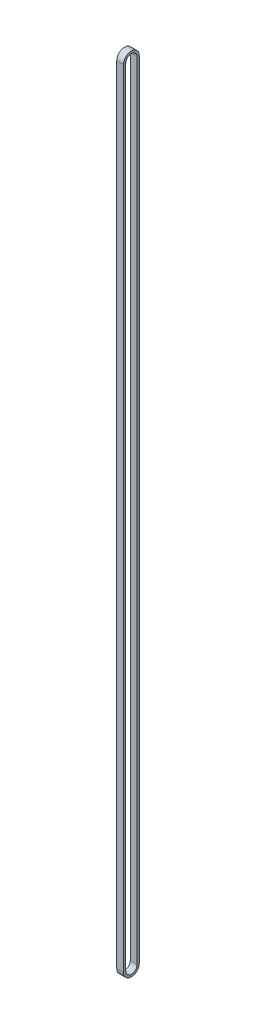
from build123d import *

# Parameters (mm, degrees)
BOSS_EXTRUDE1_DEPTH = 3


with BuildPart() as part:
    # Sketch1 → Boss-Extrude1 (new body, symmetric)
    with BuildSketch(Plane(origin=(0, 0, 0), x_dir=(0, 0, -1), z_dir=(1, 0, 0))):
        with BuildLine():
            Line((-7, 0), (-7, 698))
            ThreePointArc((-7, 698), (0, 705), (7, 698))
            Line((7, 698), (7, 0))
            ThreePointArc((7, 0), (0, -7), (-7, 0))
        make_face()
        with BuildLine():
            Line((-5, 0), (-5, 698))
            ThreePointArc((-5, 698), (0, 703), (5, 698))
            Line((5, 698), (5, 0))
            ThreePointArc((5, 0), (0, -5), (-5, 0))
        make_face(mode=Mode.SUBTRACT)
    extrude(amount=BOSS_EXTRUDE1_DEPTH, both=True)


solid = part.part
